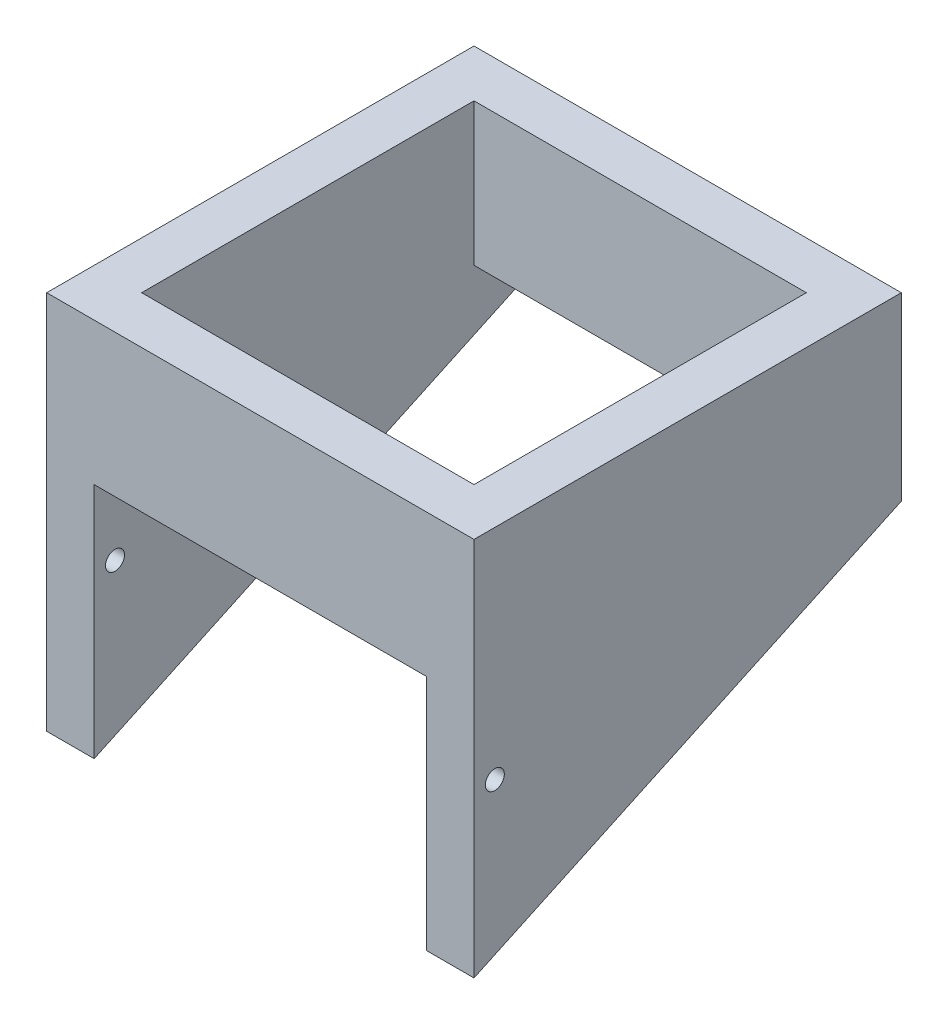
from build123d import *

# Parameters (mm, degrees)
CROQUIS1_W              = 45
CROQUIS1_H              = 45
CROQUIS1_W_2            = 35
CROQUIS1_H_2            = 35
SALIENTE_EXTRUIR1_DEPTH = 20
CORTAR_EXTRUIR1_DEPTH   = 46
CROQUIS6_W              = 35
CROQUIS6_H              = 25
CORTAR_EXTRUIR2_DEPTH   = 46
CROQUIS7_R              = 1
CORTAR_EXTRUIR3_DEPTH   = 46


with BuildPart() as part:
    # Croquis1 → Saliente-Extruir1 (new body, symmetric)
    with BuildSketch(Plane(origin=(0, 0, 0), x_dir=(1, 0, 0), z_dir=(0, 1, 0))):
        Rectangle(CROQUIS1_W, CROQUIS1_H)
        Rectangle(CROQUIS1_W_2, CROQUIS1_H_2, mode=Mode.SUBTRACT)
    extrude(amount=SALIENTE_EXTRUIR1_DEPTH, both=True)

    # Croquis3 → Cortar-Extruir1 (cut, through all)
    with BuildSketch(Plane(origin=(22.5, 0, 0), x_dir=(0, 0, -1), z_dir=(1, 0, 0))):
        Polygon((-22.5, -20), (22.5, -20), (22.5, 0.983844617), align=None)
    extrude(amount=-CORTAR_EXTRUIR1_DEPTH, mode=Mode.SUBTRACT)

    # Croquis6 → Cortar-Extruir2 (cut, through all)
    with BuildSketch(Plane.XY.offset(22.5)):
        with Locations((0, -7.5)):
            Rectangle(CROQUIS6_W, CROQUIS6_H)
    extrude(amount=-CORTAR_EXTRUIR2_DEPTH, mode=Mode.SUBTRACT)

    # Croquis7 → Cortar-Extruir3 (cut, through all)
    with BuildSketch(Plane(origin=(22.5, 0, 0), x_dir=(0, 0, -1), z_dir=(1, 0, 0))):
        with Locations((-20.307584971, -3)):
            Circle(CROQUIS7_R)
    extrude(amount=-CORTAR_EXTRUIR3_DEPTH, mode=Mode.SUBTRACT)


solid = part.part
